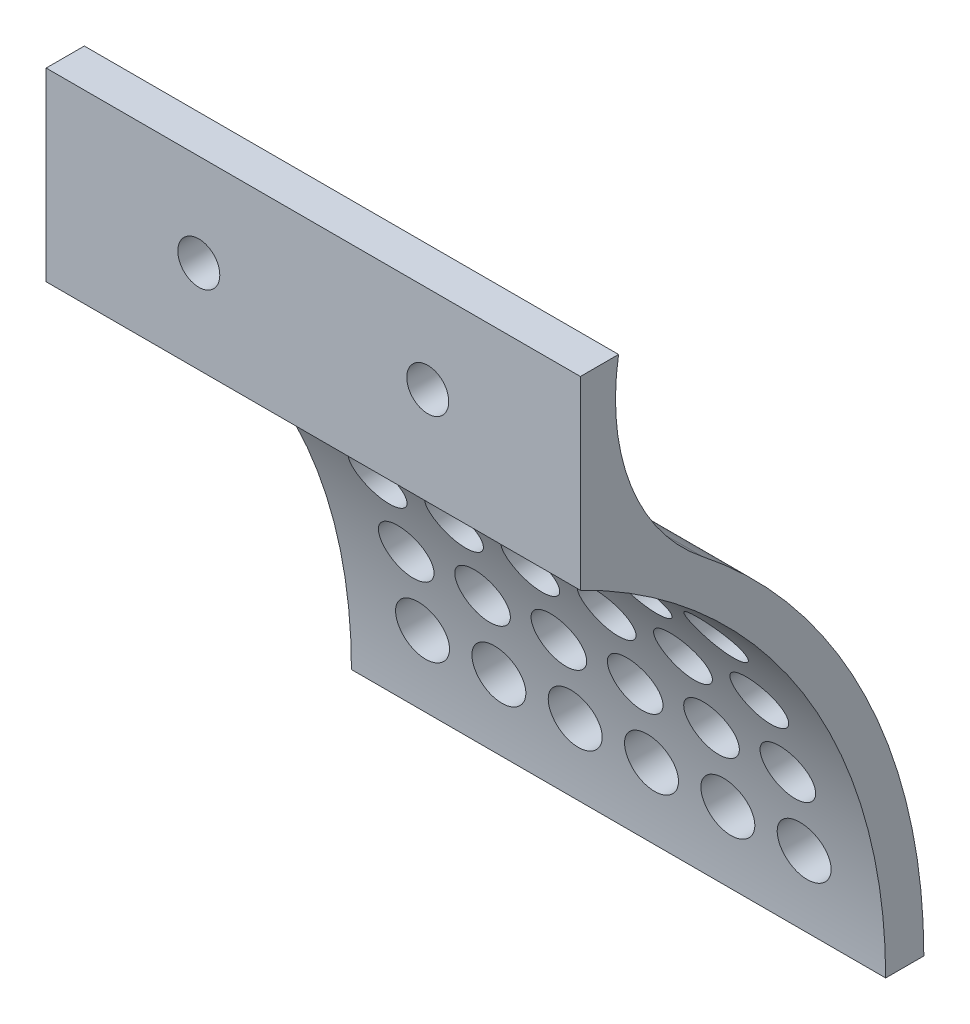
from build123d import *

# Parameters (mm, degrees)
SALIENTE_EXTRUIR1_DEPTH = 70
CROQUIS3_R              = 3.5
CORTAR_EXTRUIR3_DEPTH   = 65
CROQUIS2_R              = 2.750000002
CROQUIS2_R_2            = 2.75
CORTAR_EXTRUIR4_DEPTH   = 65


with BuildPart() as part:
    # Croquis1 → Saliente-Extruir1 (new body)
    with BuildSketch(Plane(origin=(0, 0, 0), x_dir=(0, 0, -1), z_dir=(1, 0, 0))):
        with BuildLine():
            Line((-25.193840863, 53.195024044), (-20.193840863, 53.195024044))
            ThreePointArc((-20.193840863, 53.195024044), (-18.573108699, 37.469004774), (-9.183016609, 24.750489713))
            ThreePointArc((-9.183016609, 24.750489713), (12.176943033, -1.828536951), (19.806159137, -35.062369049))
            Line((19.806159137, -35.062369049), (14.806159137, -35.062369049))
            ThreePointArc((14.806159137, -35.062369049), (3.983638383, 2.673555479), (-25.193840863, 28.937630951))
            Line((-25.193840863, 28.937630951), (-25.193840863, 53.195024044))
        make_face()
    extrude(amount=SALIENTE_EXTRUIR1_DEPTH)

    # Croquis3 → Cortar-Extruir3 (cut)
    with BuildSketch(Plane.XY.offset(-19.806159137)):
        with Locations((60, 14.750489713)):
            Circle(CROQUIS3_R)
        with Locations((50, 14.750489713)):
            Circle(CROQUIS3_R)
        with Locations((40, 14.750489713)):
            Circle(CROQUIS3_R)
        with Locations((30, 14.750489713)):
            Circle(CROQUIS3_R)
        with Locations((20, 14.750489713)):
            Circle(CROQUIS3_R)
        with Locations((10, 14.750489713)):
            Circle(CROQUIS3_R)
        with Locations((50, 4.750489713)):
            Circle(CROQUIS3_R)
        with Locations((40, 4.750489713)):
            Circle(CROQUIS3_R)
        with Locations((30, 4.750489713)):
            Circle(CROQUIS3_R)
        with Locations((20, 4.750489713)):
            Circle(CROQUIS3_R)
        with Locations((50, -5.249510287)):
            Circle(CROQUIS3_R)
        with Locations((60, 4.750489713)):
            Circle(CROQUIS3_R)
        with Locations((20, -5.249510287)):
            Circle(CROQUIS3_R)
        with Locations((30, -5.249510287)):
            Circle(CROQUIS3_R)
        with Locations((40, -5.249510287)):
            Circle(CROQUIS3_R)
        with Locations((60, -5.249510287)):
            Circle(CROQUIS3_R)
        with Locations((20, -15.249510287)):
            Circle(CROQUIS3_R)
        with Locations((30, -15.249510287)):
            Circle(CROQUIS3_R)
        with Locations((40, -15.249510287)):
            Circle(CROQUIS3_R)
        with Locations((50, -15.249510287)):
            Circle(CROQUIS3_R)
        with Locations((60, -15.249510287)):
            Circle(CROQUIS3_R)
        with Locations((20, -25.249510287)):
            Circle(CROQUIS3_R)
        with Locations((30, -25.249510287)):
            Circle(CROQUIS3_R)
        with Locations((40, -25.249510287)):
            Circle(CROQUIS3_R)
        with Locations((50, -25.249510287)):
            Circle(CROQUIS3_R)
        with Locations((60, -25.249510287)):
            Circle(CROQUIS3_R)
        with Locations((10, 4.750489713)):
            Circle(CROQUIS3_R)
        with Locations((10, -5.249510287)):
            Circle(CROQUIS3_R)
        with Locations((10, -15.249510287)):
            Circle(CROQUIS3_R)
        with Locations((10, -25.249510287)):
            Circle(CROQUIS3_R)
    extrude(amount=CORTAR_EXTRUIR3_DEPTH, mode=Mode.SUBTRACT)

    # Croquis2 → Cortar-Extruir4 (cut)
    with BuildSketch(Plane.XY.offset(25.193840863)):
        with Locations((20, 41.066327497)):
            Circle(CROQUIS2_R)
        with Locations((50, 41.717136777)):
            Circle(CROQUIS2_R_2)
    extrude(amount=-CORTAR_EXTRUIR4_DEPTH, mode=Mode.SUBTRACT)


solid = part.part
